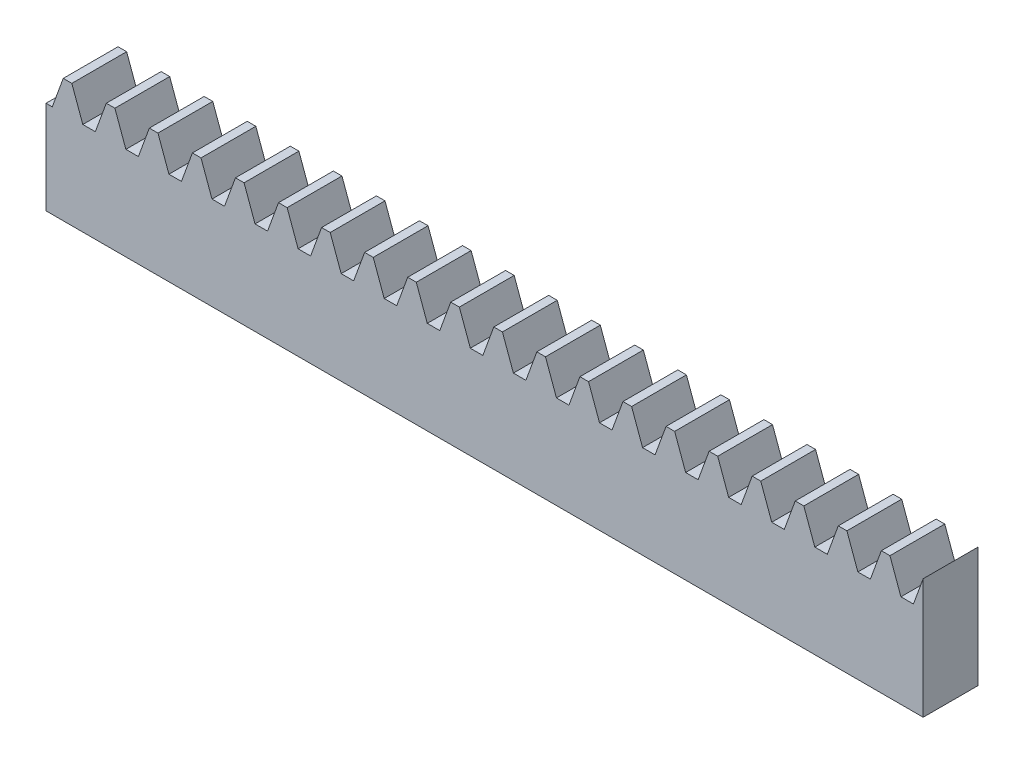
from build123d import *

# Parameters (mm, degrees)
BLANKSKE_W        = 50.8
BLANKSKE_H        = 7.14375
BLANK_DEPTH       = 3.175
TOOTHCUTSIM_DEPTH = 52.397994018
TEETHCUTS_COUNT   = 21
TEETHCUTS_PITCH   = 2.493639166


with BuildPart() as part:
    # BlankSke → Blank (new body)
    with BuildSketch(Plane.XY):
        with Locations((25.4, 3.571875)):
            Rectangle(BLANKSKE_W, BLANKSKE_H)
    extrude(amount=-BLANK_DEPTH)

    # TooCutSkeSim → ToothCutSim (cut, through all)
    with BuildSketch(Plane.XY):
        Polygon((0.362072143, 5.3975), (-0.362072143, 5.3975), (-1.006900009, 7.16915), (1.006900009, 7.16915), align=None)
    toothcutsim = extrude(amount=-TOOTHCUTSIM_DEPTH, mode=Mode.SUBTRACT)

    # TeethCuts: ToothCutSim ×21
    with Locations(*[(i * TEETHCUTS_PITCH, 0, 0) for i in range(1, TEETHCUTS_COUNT)]):
        add(toothcutsim, mode=Mode.SUBTRACT)


solid = part.part
